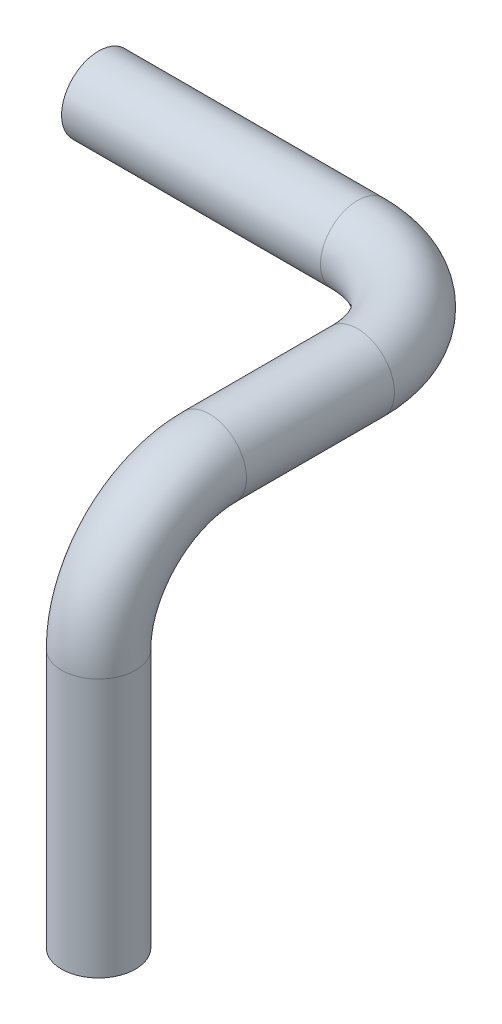
from build123d import *

# Parameters (mm, degrees)
SWEEP1_PROFILE_R = 25.4
SHELL2_T         = -2.54


with BuildPart() as part:
    # Sweep1: sweep along a curve in space
    with BuildLine() as sweep1_path:
        Line((0, 254, 0), (177.8, 254, 0))
        ThreePointArc((254, 254, 76.2), (231.681536726, 254, 22.318463274), (177.8, 254, 0))
        Line((254, 254, 76.2), (254, 254, 177.8))
        ThreePointArc((254, 177.8, 254), (254, 231.681536726, 231.681536726), (254, 254, 177.8))
        Line((254, 177.8, 254), (254, 0, 254))
    # Sweep1 profile (on start of the path) → Sweep1 (sweep)
    with BuildSketch(Plane(origin=(0, 254, 0), x_dir=(0, 0, 1), z_dir=(1, 0, 0))):
        Circle(SWEEP1_PROFILE_R)
    sweep(path=sweep1_path.line)

    # Shell2
    shell2_openings = [part.faces().sort_by_distance(p)[0] for p in [
        (254, 0, 254),
        (0, 254, 0),
    ]]
    offset(amount=SHELL2_T, openings=shell2_openings, kind=Kind.INTERSECTION)


solid = part.part
